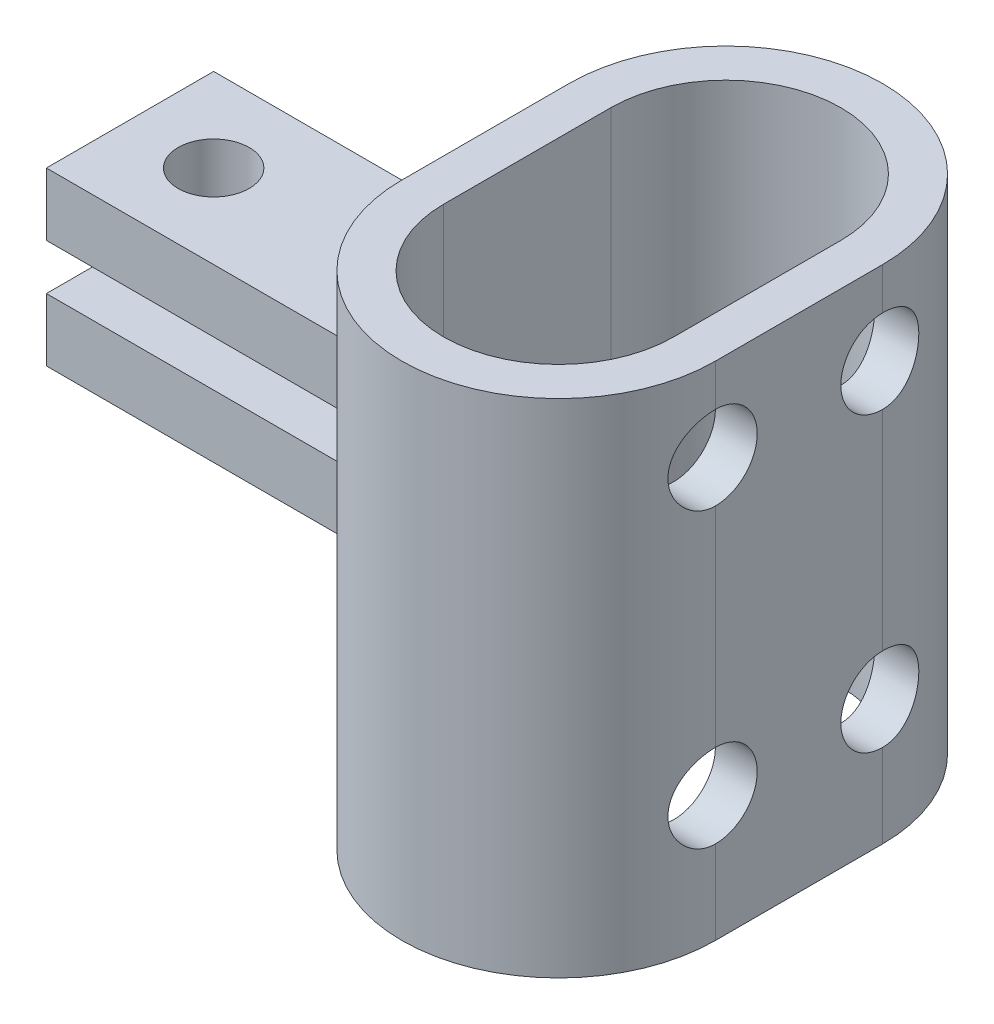
from build123d import *

# Parameters (mm, degrees)
SKETCH1_W                = 6
SKETCH1_H                = 8
SKETCH1_W_2              = 8
SKETCH1_R                = 1.7
BOSS_EXTRUDE1_DEPTH      = 3
SKETCH2_W                = 8
SKETCH2_H                = 4.1
BOSS_EXTRUDE2_DEPTH      = 3
BOSS_EXTRUDE3_DEPTH      = 8
BOSS_EXTRUDE3_DEPTH_BACK = 16
SKETCH4_R                = 2
CUT_EXTRUDE1_DEPTH       = 8


with BuildPart() as part:
    # Sketch1 → Boss-Extrude1 (new body)
    with BuildSketch(Plane(origin=(0, 0, 0), x_dir=(1, 0, 0), z_dir=(0, 1, 0))):
        with Locations((7, 0)):
            Rectangle(SKETCH1_W, SKETCH1_H)
        Rectangle(SKETCH1_W_2, SKETCH1_H)
        Circle(SKETCH1_R, mode=Mode.SUBTRACT)
    extrude(amount=BOSS_EXTRUDE1_DEPTH)

    # Sketch2 → Boss-Extrude2 (add)
    with BuildSketch(Plane(origin=(10, 0, 0), x_dir=(0, 0, -1), z_dir=(1, 0, 0))):
        with Locations((0, 0.95)):
            Rectangle(SKETCH2_W, SKETCH2_H)
    extrude(amount=BOSS_EXTRUDE2_DEPTH)

    # Mirror1: part across plane


with BuildPart() as part_1:
    add(part.part)
    add(part.part.mirror(Plane(origin=(13, -1.1, 4), x_dir=(0, 0, 1), z_dir=(0, 1, 0))))

    # Sketch3 → Boss-Extrude3 (add, two sides)
    with BuildSketch(Plane(origin=(0, 3, 0), x_dir=(1, 0, 0), z_dir=(0, 1, 0))) as boss_extrude3_sk:
        with BuildLine():
            Line((28, 4), (28, -4))
            ThreePointArc((28, -4), (20.5, -11.5), (13, -4))
            Line((13, -4), (13, 4))
            ThreePointArc((13, 4), (20.5, 11.5), (28, 4))
        make_face()
        with BuildLine():
            Line((26, 4), (26, -4))
            ThreePointArc((26, -4), (20.5, -9.5), (15, -4))
            Line((15, -4), (15, 4))
            ThreePointArc((15, 4), (20.5, 9.5), (26, 4))
        make_face(mode=Mode.SUBTRACT)
    extrude(amount=BOSS_EXTRUDE3_DEPTH)
    extrude(boss_extrude3_sk.sketch, amount=-BOSS_EXTRUDE3_DEPTH_BACK)

    # Sketch4 → Cut-Extrude1 (cut)
    with BuildSketch(Plane(origin=(28, 0, 0), x_dir=(0, 0, -1), z_dir=(1, 0, 0))):
        with Locations((-4, 7)):
            Circle(SKETCH4_R)
        with Locations((4, 7)):
            Circle(SKETCH4_R)
        with Locations((4, -7)):
            Circle(SKETCH4_R)
        with Locations((-4, -7)):
            Circle(SKETCH4_R)
    extrude(amount=-CUT_EXTRUDE1_DEPTH, mode=Mode.SUBTRACT)


solid = part_1.part
